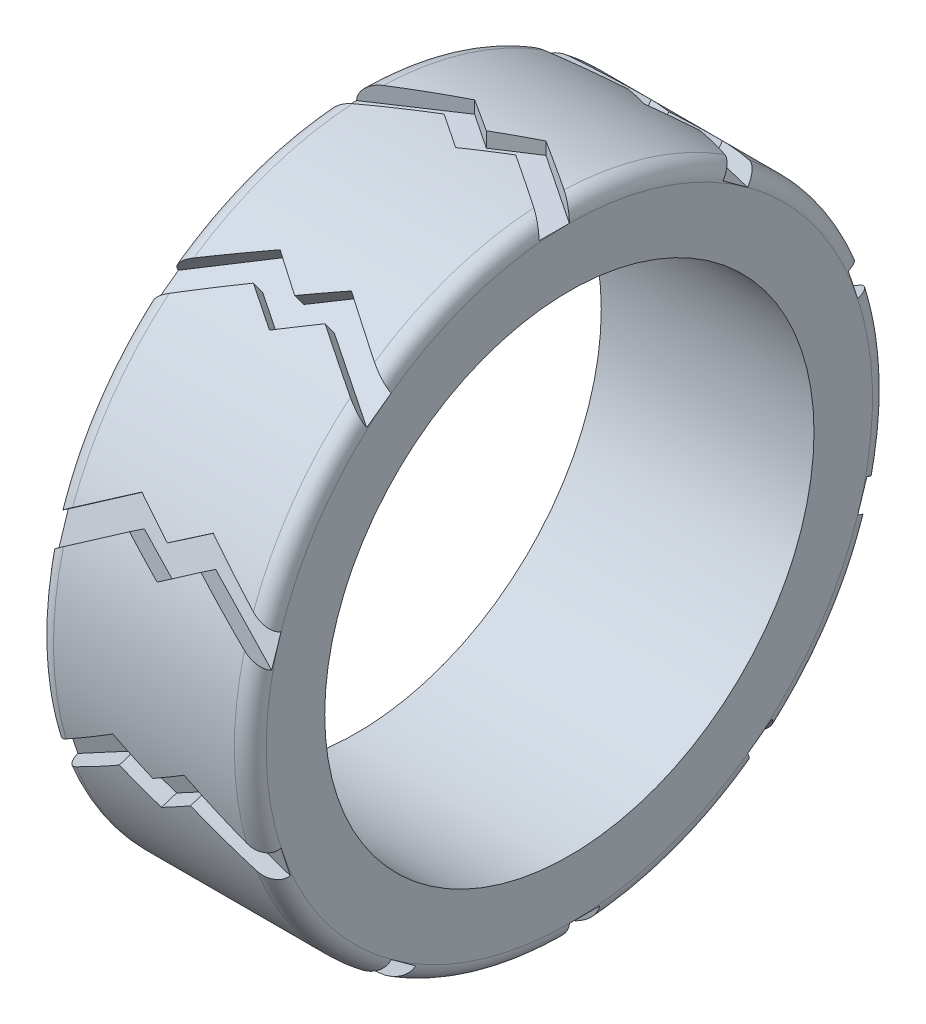
from build123d import *

# Parameters (mm, degrees)
SKETCH1_W          = 10
SKETCH1_H          = 3.5
FILLET1_R          = 0.75
FILLET2_R          = 0.75
CUT_EXTRUDE2_DEPTH = 0.75
CIRPATTERN1_COUNT  = 10


with BuildPart() as part:
    # Sketch1 → Revolve1 (revolve)
    with BuildSketch(Plane(origin=(0, 0, 0), x_dir=(1, 0, 0), z_dir=(0, 1, 0))):
        with Locations((-5, 13.25)):
            Rectangle(SKETCH1_W, SKETCH1_H)
    revolve(axis=Axis((0, 0, 0), (-1, 0, 0)))

    # Fillet1
    fillet1_edges = [part.edges().sort_by_distance(p)[0] for p in [
        (0, 0, 15),
    ]]
    fillet(fillet1_edges, radius=FILLET1_R)

    # Fillet2
    fillet2_edges = [part.edges().sort_by_distance(p)[0] for p in [
        (-10, 0, 15),
    ]]
    fillet(fillet2_edges, radius=FILLET2_R)

    # Sketch3 → Cut-Extrude2 (cut)
    with BuildSketch(Plane(origin=(0, 15, 0), x_dir=(1, 0, 0), z_dir=(0, 1, 0))):
        Polygon((-10, 0), (-6.668461645, 2.216422178), (-5.012259483, 1.108211089), (-3.317540991, 2.216422178), (0, 0), (0, -1.421653686), (-3.317540991, 0.794768492), (-5.012259483, -0.332702139), (-6.668461645, 0.773793068), (-10, -1.44262911), align=None)
    cut_extrude2 = extrude(amount=-CUT_EXTRUDE2_DEPTH, mode=Mode.SUBTRACT)

    # CirPattern1: Cut-Extrude2 ×10 about axis
    cirpattern1_axis = Axis((0, 0, 0), (1, 0, 0))
    for i in range(1, CIRPATTERN1_COUNT):
        add(cut_extrude2.rotate(cirpattern1_axis, i * 360 / CIRPATTERN1_COUNT), mode=Mode.SUBTRACT)


solid = part.part
